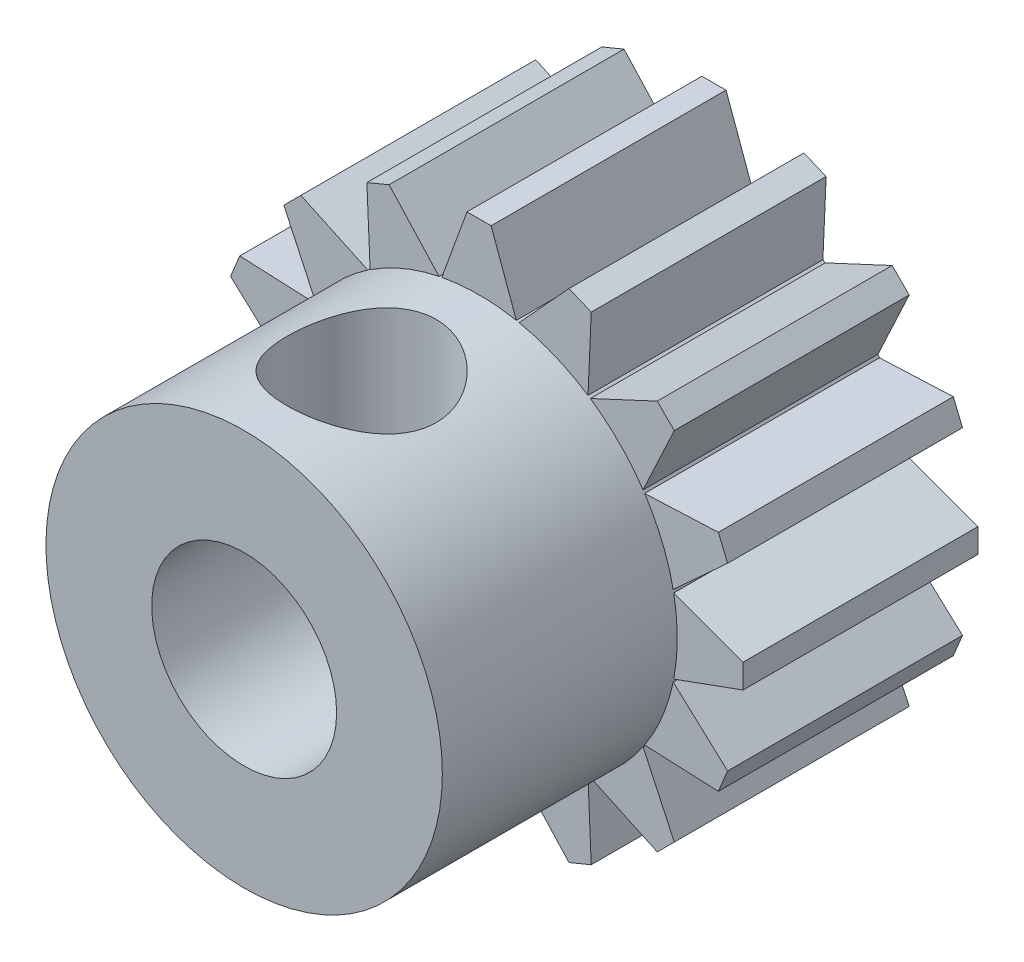
from build123d import *

# Parameters (mm, degrees)
BOSS_EXTRUDE1_DEPTH        = 6.35
SKETCH2_R                  = 5.357812451
BOSS_EXTRUDE2_DEPTH        = 6.35
F_10_CLEARANCE_HOLE1_D     = 5
F_10_CLEARANCE_HOLE1_DEPTH = 12.7
SKETCH5_W                  = 2.0193
SKETCH5_H                  = 5.66348411


with BuildPart() as part:
    # Sketch1 → Boss-Extrude1 (new body)
    with BuildSketch(Plane(origin=(0, 0, -3.175), x_dir=(-1, 0, 0), z_dir=(0, 0, -1))):
        with BuildLine():
            Line((-4.475719216, 2.94518093), (-6.469475121, 3.032230191))
            Line((-6.469475121, 3.032230191), (-6.718720366, 2.430498941))
            Line((-6.718720366, 2.430498941), (-5.247368905, 1.082253729))
            ThreePointArc((-5.247368905, 1.082253729), (-5.25486353, 1.045257315), (-5.262097316, 1.008209016))
            Line((-5.262097316, 1.008209016), (-7.137399981, 0.325654666))
            Line((-7.137399981, 0.325654666), (-7.137399981, -0.325654551))
            Line((-7.137399981, -0.325654551), (-5.262097381, -1.008208899))
            ThreePointArc((-5.262097381, -1.008208899), (-5.254863555, -1.045257412), (-5.247368888, -1.08225404))
            Line((-5.247368888, -1.08225404), (-6.718720366, -2.43049927))
            Line((-6.718720366, -2.43049927), (-6.469475121, -3.03223052))
            Line((-6.469475121, -3.03223052), (-4.475719151, -2.945181254))
            ThreePointArc((-4.475719151, -2.945181254), (-4.454858201, -2.97664122), (-4.433776122, -3.007953433))
            Line((-4.433776122, -3.007953433), (-5.277176571, -4.816631533))
            Line((-5.277176571, -4.816631533), (-4.816631353, -5.277176632))
            Line((-4.816631353, -5.277176632), (-3.007953331, -4.433776241))
            ThreePointArc((-3.007953331, -4.433776241), (-2.976641072, -4.454858352), (-2.945181059, -4.475719332))
            Line((-2.945181059, -4.475719332), (-3.032230324, -6.469475317))
            Line((-3.032230324, -6.469475317), (-2.430499074, -6.718720562))
            Line((-2.430499074, -6.718720562), (-1.082253821, -5.247369057))
            ThreePointArc((-1.082253821, -5.247369057), (-1.045257355, -5.254863691), (-1.008209005, -5.262097487))
            Line((-1.008209005, -5.262097487), (-0.325654634, -7.137400208))
            Line((-0.325654634, -7.137400208), (0.325654583, -7.137400208))
            Line((0.325654583, -7.137400208), (1.008208941, -5.262097516))
            ThreePointArc((1.008208941, -5.262097516), (1.045257356, -5.254863709), (1.082253886, -5.247369061))
            Line((1.082253886, -5.247369061), (2.430499137, -6.718720562))
            Line((2.430499137, -6.718720562), (3.032230387, -6.469475317))
            Line((3.032230387, -6.469475317), (2.945181121, -4.475719349))
            ThreePointArc((2.945181121, -4.475719349), (2.976641089, -4.454858399), (3.007953303, -4.433776319))
            Line((3.007953303, -4.433776319), (4.8166314, -5.277176767))
            Line((4.8166314, -5.277176767), (5.277176499, -4.816631549))
            Line((5.277176499, -4.816631549), (4.433776123, -3.007953559))
            ThreePointArc((4.433776123, -3.007953559), (4.454858245, -2.976641285), (4.475719236, -2.945181257))
            Line((4.475719236, -2.945181257), (6.469475184, -3.03223052))
            Line((6.469475184, -3.03223052), (6.718720429, -2.43049927))
            Line((6.718720429, -2.43049927), (5.247368971, -1.08225406))
            ThreePointArc((5.247368971, -1.08225406), (5.254863613, -1.045257562), (5.262097415, -1.008209179))
            Line((5.262097415, -1.008209179), (7.137400075, -0.32565483))
            Line((7.137400075, -0.32565483), (7.137400075, 0.325654387))
            Line((7.137400075, 0.325654387), (5.26209746, 1.008208717))
            ThreePointArc((5.26209746, 1.008208717), (5.254863645, 1.045257174), (5.247368989, 1.082253746))
            Line((5.247368989, 1.082253746), (6.718720429, 2.430498941))
            Line((6.718720429, 2.430498941), (6.469475184, 3.032230191))
            Line((6.469475184, 3.032230191), (4.475719304, 2.945180929))
            ThreePointArc((4.475719304, 2.945180929), (4.454858329, 2.976640935), (4.433776224, 3.007953186))
            Line((4.433776224, 3.007953186), (5.277176634, 4.816631204))
            Line((5.277176634, 4.816631204), (4.816631416, 5.277176303))
            Line((4.816631416, 5.277176303), (3.007953499, 4.433775961))
            ThreePointArc((3.007953499, 4.433775961), (2.976641191, 4.454858106), (2.945181127, 4.47571912))
            Line((2.945181127, 4.47571912), (3.032230387, 6.469474988))
            Line((3.032230387, 6.469474988), (2.430499137, 6.718720233))
            Line((2.430499137, 6.718720233), (1.082253963, 5.24736882))
            ThreePointArc((1.082253963, 5.24736882), (1.045257437, 5.254863468), (1.008209026, 5.262097275))
            Line((1.008209026, 5.262097275), (0.325654697, 7.137399816))
            Line((0.325654697, 7.137399816), (-0.32565452, 7.137399816))
            Line((-0.32565452, 7.137399816), (-1.008208848, 5.262097292))
            ThreePointArc((-1.008208848, 5.262097292), (-1.045257316, 5.254863474), (-1.082253899, 5.247368816))
            Line((-1.082253899, 5.247368816), (-2.430499074, 6.718720233))
            Line((-2.430499074, 6.718720233), (-3.032230324, 6.469474988))
            Line((-3.032230324, 6.469474988), (-2.945181062, 4.475719106))
            ThreePointArc((-2.945181062, 4.475719106), (-2.976641066, 4.454858131), (-3.007953316, 4.433776026))
            Line((-3.007953316, 4.433776026), (-4.816631337, 5.277176438))
            Line((-4.816631337, 5.277176438), (-5.277176436, 4.81663122))
            Line((-5.277176436, 4.81663122), (-4.433776079, 3.007953271))
            ThreePointArc((-4.433776079, 3.007953271), (-4.454858213, 2.976640978), (-4.475719216, 2.94518093))
        make_face()
    extrude(amount=-BOSS_EXTRUDE1_DEPTH)

    # Sketch2 → Boss-Extrude2 (add)
    with BuildSketch(Plane.XY.offset(3.175)):
        with Locations((-1.2e-08, 5.2e-08)):
            Circle(SKETCH2_R)
    extrude(amount=BOSS_EXTRUDE2_DEPTH)

    # #10 Clearance Hole1
    with Locations(Plane.XY.offset(9.525)):
        with Locations((0, 0)):
            Hole(F_10_CLEARANCE_HOLE1_D / 2, depth=F_10_CLEARANCE_HOLE1_DEPTH)

    # Sketch5 → #21 (0.159) Diameter Hole1 (revolve, cut)
    with BuildSketch(Plane(origin=(0, 1.473915707, 6.35), x_dir=(0, 0, -1), z_dir=(1, 0, 0))):
        with Locations((1.00965, 2.831742055)):
            Rectangle(SKETCH5_W, SKETCH5_H)
    revolve(axis=Axis((0, -4.876084293, 6.35), (0, 1, 0)), mode=Mode.SUBTRACT)


solid = part.part
